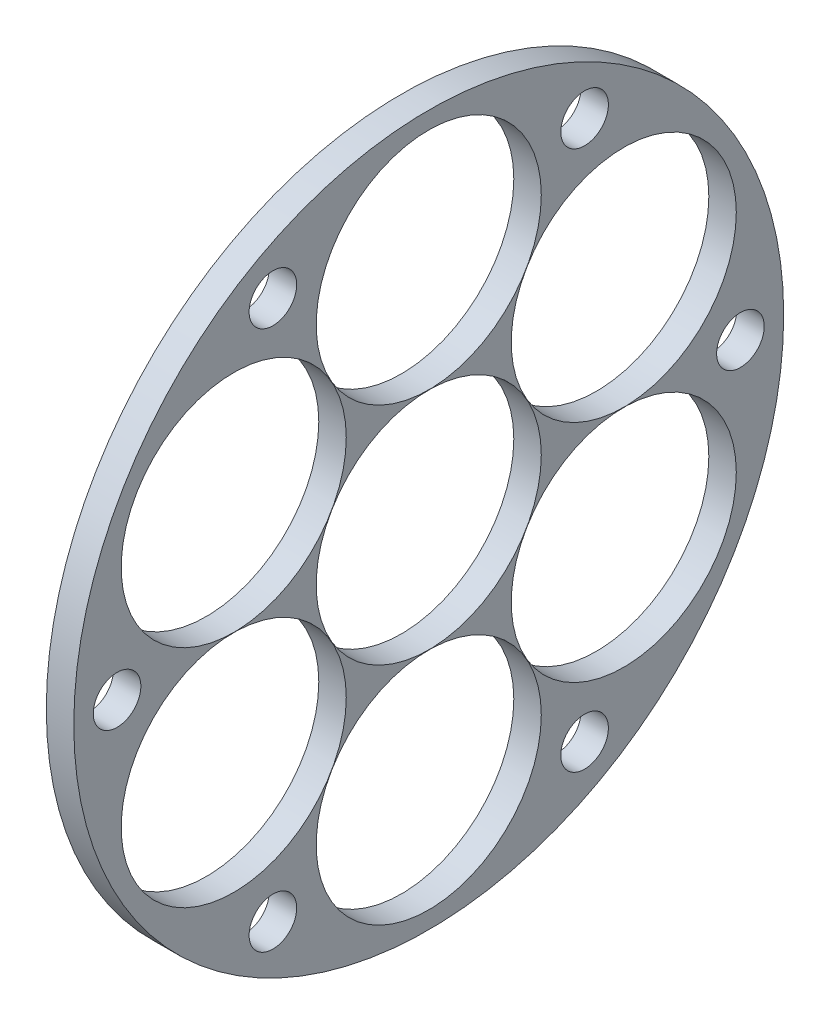
from build123d import *

# Parameters (mm, degrees)
SKETCH1_R           = 41
BOSS_EXTRUDE1_DEPTH = 3.175
SKETCH2_R           = 13
SKETCH2_R_2         = 2.75
CUT_EXTRUDE1_DEPTH  = 25


with BuildPart() as part:
    # Sketch1 → Boss-Extrude1 (new body)
    with BuildSketch(Plane(origin=(0, 0, 0), x_dir=(0, 0, -1), z_dir=(1, 0, 0))):
        Circle(SKETCH1_R)
    extrude(amount=BOSS_EXTRUDE1_DEPTH)

    # Sketch2 → Cut-Extrude1 (cut)
    with BuildSketch(Plane(origin=(3.175, 0, 0), x_dir=(0, 0, -1), z_dir=(1, 0, 0))):
        Circle(SKETCH2_R)
        with Locations((0, 26.01)):
            Circle(SKETCH2_R)
        with Locations((22.525320752, 13.005)):
            Circle(SKETCH2_R)
        with Locations((22.525320752, -13.005)):
            Circle(SKETCH2_R)
        with Locations((0, -26.01)):
            Circle(SKETCH2_R)
        with Locations((-22.525320752, -13.005)):
            Circle(SKETCH2_R)
        with Locations((-22.525320752, 13.005)):
            Circle(SKETCH2_R)
        with Locations((-18, 31.176914536)):
            Circle(SKETCH2_R_2)
        with Locations((18, 31.176914536)):
            Circle(SKETCH2_R_2)
        with Locations((36, 0)):
            Circle(SKETCH2_R_2)
        with Locations((18, -31.176914536)):
            Circle(SKETCH2_R_2)
        with Locations((-18, -31.176914536)):
            Circle(SKETCH2_R_2)
        with Locations((-36, 0)):
            Circle(SKETCH2_R_2)
    extrude(amount=-CUT_EXTRUDE1_DEPTH, mode=Mode.SUBTRACT)


solid = part.part
